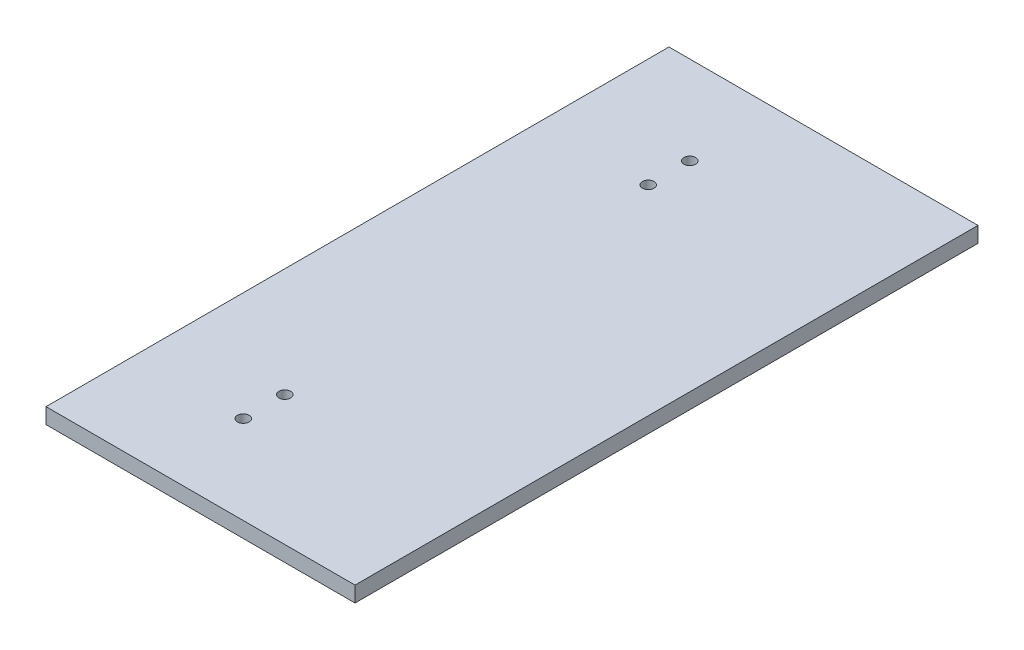
from build123d import *

# Parameters (mm, degrees)
SKETCH1_W           = 251.99999892
SKETCH1_H           = 508
SKETCH1_R           = 4.7625
BOSS_EXTRUDE4_DEPTH = 12.7


with BuildPart() as part:
    # Sketch1 → Boss-Extrude4 (new body)
    with BuildSketch(Plane(origin=(0, 0, 0), x_dir=(1, 0, 0), z_dir=(0, 1, 0))):
        with Locations((-203.580065595, -35.673837084)):
            Rectangle(SKETCH1_W, SKETCH1_H)
        with Locations((-240.680065055, 112.492829583)):
            Circle(SKETCH1_R, mode=Mode.SUBTRACT)
        with Locations((-240.680065055, 146.35949625)):
            Circle(SKETCH1_R, mode=Mode.SUBTRACT)
        with Locations((-240.680065055, -183.84050375)):
            Circle(SKETCH1_R, mode=Mode.SUBTRACT)
        with Locations((-240.680065055, -217.707170417)):
            Circle(SKETCH1_R, mode=Mode.SUBTRACT)
    extrude(amount=BOSS_EXTRUDE4_DEPTH)


solid = part.part
